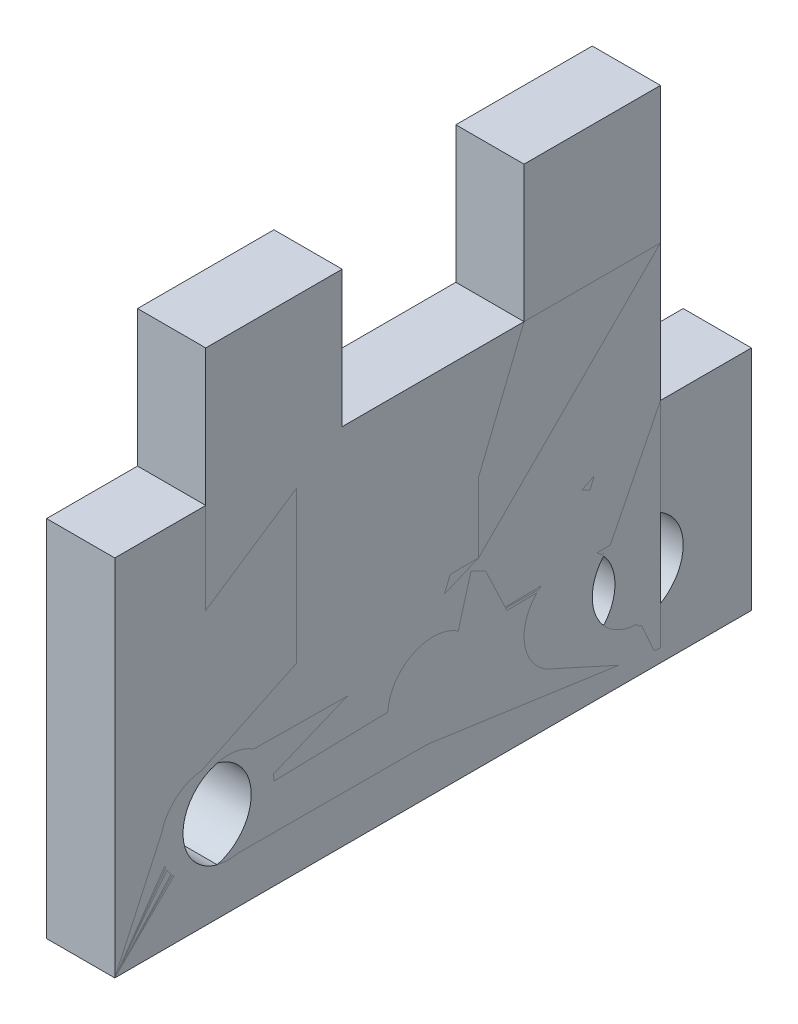
from build123d import *

# Parameters (mm, degrees)
BOSS_EXTRUDE1_DEPTH = 15
SKETCH5_R           = 10
CUT_EXTRUDE1_DEPTH  = 15
SKETCH7_R           = 10
BOSS_EXTRUDE2_DEPTH = 15


with BuildPart() as part:
    # Sketch3 → Boss-Extrude1 (new body)
    with BuildSketch(Plane(origin=(0, 0, 0), x_dir=(0, 0, -1), z_dir=(1, 0, 0))):
        Polygon((0, 0), (120, 0), (120, 80), (80, 80), (80, 40), (40, 40), (40, 80), (0, 80), align=None)
    extrude(amount=BOSS_EXTRUDE1_DEPTH)

    # Sketch5 → Cut-Extrude1 (cut)
    with BuildSketch(Plane.ZY):
        with Locations((-100, 20)):
            Circle(SKETCH5_R)
        with Locations((-20, 20)):
            Circle(SKETCH5_R)
    extrude(amount=-CUT_EXTRUDE1_DEPTH, mode=Mode.SUBTRACT)


with BuildPart() as body_2:
    # Sketch7 → Boss-Extrude2 (new body)
    with BuildSketch(Plane(origin=(0, 0, 0), x_dir=(0, 0, -1), z_dir=(1, 0, 0))):
        Polygon((0, 0), (140, 0), (140, 50), (120, 50), (120, 110), (90, 110), (90, 80), (50, 80), (50, 110), (20, 110), (20, 60), (0, 60), align=None)
        with Locations((25, 20)):
            Circle(SKETCH7_R, mode=Mode.SUBTRACT)
        with Locations((70, 20)):
            Circle(SKETCH7_R, mode=Mode.SUBTRACT)
        with Locations((115, 20)):
            Circle(SKETCH7_R, mode=Mode.SUBTRACT)
    extrude(amount=BOSS_EXTRUDE2_DEPTH)


solid = Compound([part.part, body_2.part])
